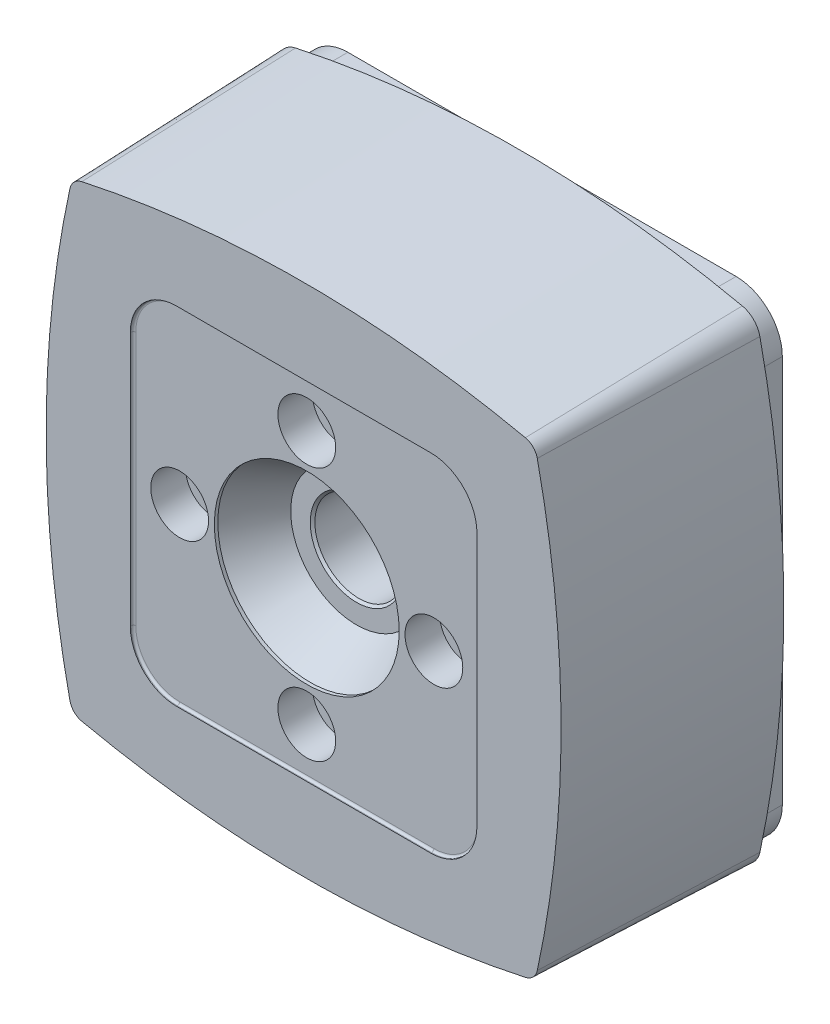
from build123d import *

# Parameters (mm, degrees)
EXTRUDE1_DEPTH      = 93.15
EXTRUDE1_TAPER      = 2
CUT_EXTRUDE1_DEPTH  = 1.37
FILLET1_R           = 1
SKETCH3_R           = 40
CUT_EXTRUDE2_DEPTH  = 1.5
SKETCH4_R           = 19
CUT_EXTRUDE3_DEPTH  = 175.5
SKETCH5_R           = 40
CUT_EXTRUDE4_DEPTH  = 20
CUT_EXTRUDE4_DRAFT  = -30
CHAMFER1_SIZE       = 1
EXTRUDE2_DEPTH      = 10
SKETCH7_R           = 19
CUT_EXTRUDE5_DEPTH  = 77
SKETCH8_R           = 12.5
CUT_EXTRUDE6_DEPTH  = 15
SKETCH9_R           = 5.857190083
SKETCH9_R_2         = 6.949090909
SKETCH9_R_3         = 6.10677686
SKETCH9_R_4         = 7.5
CUT_EXTRUDE7_DEPTH  = 15
SKETCH10_R          = 7.5
CUT_EXTRUDE8_DEPTH  = 201
SKETCH11_R          = 12.5
SKETCH11_R_2        = 9.5
CUT_EXTRUDE9_DEPTH  = 1.5
SKETCH12_R          = 8
CUT_EXTRUDE10_DEPTH = 70
SKETCH14_R          = 7
CUT_EXTRUDE12_DEPTH = 40


with BuildPart() as part:
    # Sketch1 → Extrude1 (new body)
    with BuildSketch(Plane.XY):
        with BuildLine():
            ThreePointArc((104.294853405, -96.642942622), (114.66, 0), (104.294853405, 96.642942622))
            ThreePointArc((104.294853405, 96.642942622), (101.593364666, 101.593364666), (96.642942622, 104.294853405))
            ThreePointArc((96.642942622, 104.294853405), (0, 114.66), (-96.642942622, 104.294853405))
            ThreePointArc((-96.642942622, 104.294853405), (-101.593364666, 101.593364666), (-104.294853405, 96.642942622))
            ThreePointArc((-104.294853405, 96.642942622), (-114.66, 0), (-104.294853405, -96.642942622))
            ThreePointArc((-104.294853405, -96.642942622), (-101.593364666, -101.593364666), (-96.642942622, -104.294853405))
            ThreePointArc((-96.642942622, -104.294853405), (0, -114.66), (96.642942622, -104.294853405))
            ThreePointArc((96.642942622, -104.294853405), (101.593364666, -101.593364666), (104.294853405, -96.642942622))
        make_face()
    extrude(amount=EXTRUDE1_DEPTH, taper=EXTRUDE1_TAPER)

    # Sketch2 → Cut-Extrude1 (cut)
    with BuildSketch(Plane.XY.offset(93.15)):
        with BuildLine():
            Line((-55, -75), (55, -75))
            ThreePointArc((55, -75), (69.142135624, -69.142135624), (75, -55))
            Line((75, -55), (75, 55))
            ThreePointArc((75, 55), (69.142135624, 69.142135624), (55, 75))
            Line((55, 75), (-55, 75))
            ThreePointArc((-55, 75), (-69.142135624, 69.142135624), (-75, 55))
            Line((-75, 55), (-75, -55))
            ThreePointArc((-75, -55), (-69.142135624, -69.142135624), (-55, -75))
        make_face()
    extrude(amount=-CUT_EXTRUDE1_DEPTH, mode=Mode.SUBTRACT)

    # Fillet1
    fillet1_edges = [part.edges().sort_by_distance(p)[0] for p in [
        (69.142135624, 69.142135624, 91.78),
        (75, 0, 91.78),
        (69.142135624, -69.142135624, 91.78),
        (0, -75, 91.78),
        (-69.142135624, -69.142135624, 91.78),
        (-75, 0, 91.78),
        (-69.142135624, 69.142135624, 91.78),
        (0, 75, 91.78),
    ]]
    fillet(fillet1_edges, radius=FILLET1_R)

    # Sketch3 → Cut-Extrude2 (cut)
    with BuildSketch(Plane.XY.offset(91.78)):
        Circle(SKETCH3_R)
    extrude(amount=-CUT_EXTRUDE2_DEPTH, mode=Mode.SUBTRACT)

    # Sketch4 → Cut-Extrude3 (cut)
    with BuildSketch(Plane.XY.offset(90.28)):
        Circle(SKETCH4_R)
    extrude(amount=-CUT_EXTRUDE3_DEPTH, mode=Mode.SUBTRACT)


with BuildPart() as cut_extrude4_tool:
    # Sketch5 → Cut-Extrude4 (with draft: the straight prism first)
    with BuildSketch(Plane.XY.offset(90.28)):
        Circle(SKETCH5_R)
    extrude(amount=-CUT_EXTRUDE4_DEPTH)
    # Cut-Extrude4: the draft: its side faces are tilted about the plane it starts from
    cut_extrude4_sides = [cut_extrude4_tool.faces().sort_by_distance(p)[0] for p in [
        (-40, 0, 80.28),
    ]]
    draft(cut_extrude4_sides, Plane.XY.offset(90.28), CUT_EXTRUDE4_DRAFT)


with BuildPart() as part_1:
    add(part.part)

    # Cut-Extrude4: cut by cut_extrude4_tool
    add(cut_extrude4_tool.part, mode=Mode.SUBTRACT)

    # Chamfer1
    chamfer1_edges = [part_1.edges().sort_by_distance(p)[0] for p in [
        (-19, 0, 70.28),
    ]]
    chamfer(chamfer1_edges, length=CHAMFER1_SIZE)

    # Sketch6 → Extrude2 (add)
    with BuildSketch(Plane(origin=(0, 0, 0), x_dir=(-1, 0, 0), z_dir=(0, 0, -1))):
        with BuildLine():
            Line((-84, -104), (84, -104))
            ThreePointArc((84, -104), (98.142135624, -98.142135624), (104, -84))
            Line((104, -84), (104, 84))
            ThreePointArc((104, 84), (98.142135624, 98.142135624), (84, 104))
            Line((84, 104), (-84, 104))
            ThreePointArc((-84, 104), (-98.142135624, 98.142135624), (-104, 84))
            Line((-104, 84), (-104, -84))
            ThreePointArc((-104, -84), (-98.142135624, -98.142135624), (-84, -104))
        make_face()
    extrude(amount=EXTRUDE2_DEPTH)

    # Sketch7 → Cut-Extrude5 (cut)
    with BuildSketch(Plane.XY):
        Circle(SKETCH7_R)
    extrude(amount=-CUT_EXTRUDE5_DEPTH, mode=Mode.SUBTRACT)

    # Sketch8 → Cut-Extrude6 (cut)
    with BuildSketch(Plane.XY.offset(91.78)):
        with Locations((-55, 0)):
            Circle(SKETCH8_R)
        with Locations((55, 0)):
            Circle(SKETCH8_R)
        with Locations((0, 55)):
            Circle(SKETCH8_R)
        with Locations((0, -55)):
            Circle(SKETCH8_R)
    extrude(amount=-CUT_EXTRUDE6_DEPTH, mode=Mode.SUBTRACT)

    # Sketch9 → Cut-Extrude7 (cut)
    with BuildSketch(Plane.XY.offset(76.78)):
        with Locations((0, 55)):
            Circle(SKETCH9_R)
        with Locations((-55, 0)):
            Circle(SKETCH9_R_2)
        with Locations((55, 0)):
            Circle(SKETCH9_R_3)
        with Locations((0, -55)):
            Circle(SKETCH9_R_4)
    extrude(amount=-CUT_EXTRUDE7_DEPTH, mode=Mode.SUBTRACT)

    # Sketch10 → Cut-Extrude8 (cut)
    with BuildSketch(Plane.XY.offset(76.78)):
        with Locations((0, 55)):
            Circle(SKETCH10_R)
        with Locations((55, 0)):
            Circle(SKETCH10_R)
        with Locations((0, -55)):
            Circle(SKETCH10_R)
        with Locations((-55, 0)):
            Circle(SKETCH10_R)
    extrude(amount=-CUT_EXTRUDE8_DEPTH, mode=Mode.SUBTRACT)

    # Sketch11 → Cut-Extrude9 (cut)
    # profile 1 of 12: a face of its own
    with BuildSketch(Plane(origin=(0, 0, -10), x_dir=(-1, 0, 0), z_dir=(0, 0, -1))):
        with Locations((-84, -84)):
            Circle(SKETCH11_R)
        with Locations((-84, -84)):
            Circle(SKETCH11_R_2, mode=Mode.SUBTRACT)
    # profile 2 of 12: a face of its own
    with BuildSketch(Plane(origin=(0, 0, -10), x_dir=(-1, 0, 0), z_dir=(0, 0, -1))):
        with Locations((-28, -84)):
            Circle(SKETCH11_R)
        with Locations((-28, -84)):
            Circle(SKETCH11_R_2, mode=Mode.SUBTRACT)
    # profile 3 of 12: a face of its own
    with BuildSketch(Plane(origin=(0, 0, -10), x_dir=(-1, 0, 0), z_dir=(0, 0, -1))):
        with Locations((28, -84)):
            Circle(SKETCH11_R)
        with Locations((28, -84)):
            Circle(SKETCH11_R_2, mode=Mode.SUBTRACT)
    # profile 4 of 12: a face of its own
    with BuildSketch(Plane(origin=(0, 0, -10), x_dir=(-1, 0, 0), z_dir=(0, 0, -1))):
        with Locations((84, -84)):
            Circle(SKETCH11_R)
        with Locations((84, -84)):
            Circle(SKETCH11_R_2, mode=Mode.SUBTRACT)
    # profile 5 of 12: a face of its own
    with BuildSketch(Plane(origin=(0, 0, -10), x_dir=(-1, 0, 0), z_dir=(0, 0, -1))):
        with Locations((84, -28)):
            Circle(SKETCH11_R)
        with Locations((84, -28)):
            Circle(SKETCH11_R_2, mode=Mode.SUBTRACT)
    # profile 6 of 12: a face of its own
    with BuildSketch(Plane(origin=(0, 0, -10), x_dir=(-1, 0, 0), z_dir=(0, 0, -1))):
        with Locations((84, 28)):
            Circle(SKETCH11_R)
        with Locations((84, 28)):
            Circle(SKETCH11_R_2, mode=Mode.SUBTRACT)
    # profile 7 of 12: a face of its own
    with BuildSketch(Plane(origin=(0, 0, -10), x_dir=(-1, 0, 0), z_dir=(0, 0, -1))):
        with Locations((84, 84)):
            Circle(SKETCH11_R)
        with Locations((84, 84)):
            Circle(SKETCH11_R_2, mode=Mode.SUBTRACT)
    # profile 8 of 12: a face of its own
    with BuildSketch(Plane(origin=(0, 0, -10), x_dir=(-1, 0, 0), z_dir=(0, 0, -1))):
        with Locations((28, 84)):
            Circle(SKETCH11_R)
        with Locations((28, 84)):
            Circle(SKETCH11_R_2, mode=Mode.SUBTRACT)
    # profile 9 of 12: a face of its own
    with BuildSketch(Plane(origin=(0, 0, -10), x_dir=(-1, 0, 0), z_dir=(0, 0, -1))):
        with Locations((-28, 84)):
            Circle(SKETCH11_R)
        with Locations((-28, 84)):
            Circle(SKETCH11_R_2, mode=Mode.SUBTRACT)
    # profile 10 of 12: a face of its own
    with BuildSketch(Plane(origin=(0, 0, -10), x_dir=(-1, 0, 0), z_dir=(0, 0, -1))):
        with Locations((-84, 84)):
            Circle(SKETCH11_R)
        with Locations((-84, 84)):
            Circle(SKETCH11_R_2, mode=Mode.SUBTRACT)
    # profile 11 of 12: a face of its own
    with BuildSketch(Plane(origin=(0, 0, -10), x_dir=(-1, 0, 0), z_dir=(0, 0, -1))):
        with Locations((-84, 28)):
            Circle(SKETCH11_R)
        with Locations((-84, 28)):
            Circle(SKETCH11_R_2, mode=Mode.SUBTRACT)
    # profile 12 of 12: a face of its own
    with BuildSketch(Plane(origin=(0, 0, -10), x_dir=(-1, 0, 0), z_dir=(0, 0, -1))):
        with Locations((-84, -28)):
            Circle(SKETCH11_R)
        with Locations((-84, -28)):
            Circle(SKETCH11_R_2, mode=Mode.SUBTRACT)
    extrude(amount=-CUT_EXTRUDE9_DEPTH, mode=Mode.SUBTRACT)

    # Sketch12 → Cut-Extrude10 (cut)
    with BuildSketch(Plane(origin=(0, 0, -10), x_dir=(-1, 0, 0), z_dir=(0, 0, -1))):
        with Locations((-84, -84)):
            Circle(SKETCH12_R)
        with Locations((-28, -84)):
            Circle(SKETCH12_R)
        with Locations((28, -84)):
            Circle(SKETCH12_R)
        with Locations((84, -84)):
            Circle(SKETCH12_R)
        with Locations((84, -28)):
            Circle(SKETCH12_R)
        with Locations((84, 28)):
            Circle(SKETCH12_R)
        with Locations((84, 84)):
            Circle(SKETCH12_R)
        with Locations((28, 84)):
            Circle(SKETCH12_R)
        with Locations((-28, 84)):
            Circle(SKETCH12_R)
        with Locations((-84, 84)):
            Circle(SKETCH12_R)
        with Locations((-84, 28)):
            Circle(SKETCH12_R)
        with Locations((-84, -28)):
            Circle(SKETCH12_R)
    extrude(amount=-CUT_EXTRUDE10_DEPTH, mode=Mode.SUBTRACT)

    # Cut-Extrude11 cone 1 section (through the dimple's axis) → Cut-Extrude11 (revolve, cut)
    with BuildSketch(Plane(origin=(-84, 84, 60), x_dir=(0, 1, 0), z_dir=(1, 0, 0))):
        Polygon((0, 0), (8, 0), (0, 4.618802154), align=None)
    revolve(axis=Axis((-84, 84, 60), (0, 0, 1)), mode=Mode.SUBTRACT)

    # Cut-Extrude11 cone 2 section (through the dimple's axis) → Cut-Extrude11 cone 2 (revolve, cut)
    with BuildSketch(Plane(origin=(-28, 84, 60), x_dir=(0, 1, 0), z_dir=(1, 0, 0))):
        Polygon((0, 0), (8, 0), (0, 4.618802154), align=None)
    revolve(axis=Axis((-28, 84, 60), (0, 0, 1)), mode=Mode.SUBTRACT)

    # Cut-Extrude11 cone 3 section (through the dimple's axis) → Cut-Extrude11 cone 3 (revolve, cut)
    with BuildSketch(Plane(origin=(28, 84, 60), x_dir=(0, 1, 0), z_dir=(1, 0, 0))):
        Polygon((0, 0), (8, 0), (0, 4.618802154), align=None)
    revolve(axis=Axis((28, 84, 60), (0, 0, 1)), mode=Mode.SUBTRACT)

    # Cut-Extrude11 cone 4 section (through the dimple's axis) → Cut-Extrude11 cone 4 (revolve, cut)
    with BuildSketch(Plane(origin=(84, 84, 60), x_dir=(0, 1, 0), z_dir=(1, 0, 0))):
        Polygon((0, 0), (8, 0), (0, 4.618802154), align=None)
    revolve(axis=Axis((84, 84, 60), (0, 0, 1)), mode=Mode.SUBTRACT)

    # Cut-Extrude11 cone 5 section (through the dimple's axis) → Cut-Extrude11 cone 5 (revolve, cut)
    with BuildSketch(Plane(origin=(84, 28, 60), x_dir=(0, 1, 0), z_dir=(1, 0, 0))):
        Polygon((0, 0), (8, 0), (0, 4.618802154), align=None)
    revolve(axis=Axis((84, 28, 60), (0, 0, 1)), mode=Mode.SUBTRACT)

    # Cut-Extrude11 cone 6 section (through the dimple's axis) → Cut-Extrude11 cone 6 (revolve, cut)
    with BuildSketch(Plane(origin=(84, -28, 60), x_dir=(0, 1, 0), z_dir=(1, 0, 0))):
        Polygon((0, 0), (8, 0), (0, 4.618802154), align=None)
    revolve(axis=Axis((84, -28, 60), (0, 0, 1)), mode=Mode.SUBTRACT)

    # Cut-Extrude11 cone 7 section (through the dimple's axis) → Cut-Extrude11 cone 7 (revolve, cut)
    with BuildSketch(Plane(origin=(-84, 28, 60), x_dir=(0, 1, 0), z_dir=(1, 0, 0))):
        Polygon((0, 0), (8, 0), (0, 4.618802154), align=None)
    revolve(axis=Axis((-84, 28, 60), (0, 0, 1)), mode=Mode.SUBTRACT)

    # Cut-Extrude11 cone 8 section (through the dimple's axis) → Cut-Extrude11 cone 8 (revolve, cut)
    with BuildSketch(Plane(origin=(-84, -28, 60), x_dir=(0, 1, 0), z_dir=(1, 0, 0))):
        Polygon((0, 0), (8, 0), (0, 4.618802154), align=None)
    revolve(axis=Axis((-84, -28, 60), (0, 0, 1)), mode=Mode.SUBTRACT)

    # Cut-Extrude11 cone 9 section (through the dimple's axis) → Cut-Extrude11 cone 9 (revolve, cut)
    with BuildSketch(Plane(origin=(84, -84, 60), x_dir=(0, 1, 0), z_dir=(1, 0, 0))):
        Polygon((0, 0), (8, 0), (0, 4.618802154), align=None)
    revolve(axis=Axis((84, -84, 60), (0, 0, 1)), mode=Mode.SUBTRACT)

    # Cut-Extrude11 cone 10 section (through the dimple's axis) → Cut-Extrude11 cone 10 (revolve, cut)
    with BuildSketch(Plane(origin=(28, -84, 60), x_dir=(0, 1, 0), z_dir=(1, 0, 0))):
        Polygon((0, 0), (8, 0), (0, 4.618802154), align=None)
    revolve(axis=Axis((28, -84, 60), (0, 0, 1)), mode=Mode.SUBTRACT)

    # Cut-Extrude11 cone 11 section (through the dimple's axis) → Cut-Extrude11 cone 11 (revolve, cut)
    with BuildSketch(Plane(origin=(-28, -84, 60), x_dir=(0, 1, 0), z_dir=(1, 0, 0))):
        Polygon((0, 0), (8, 0), (0, 4.618802154), align=None)
    revolve(axis=Axis((-28, -84, 60), (0, 0, 1)), mode=Mode.SUBTRACT)

    # Cut-Extrude11 cone 12 section (through the dimple's axis) → Cut-Extrude11 cone 12 (revolve, cut)
    with BuildSketch(Plane(origin=(-84, -84, 60), x_dir=(0, 1, 0), z_dir=(1, 0, 0))):
        Polygon((0, 0), (8, 0), (0, 4.618802154), align=None)
    revolve(axis=Axis((-84, -84, 60), (0, 0, 1)), mode=Mode.SUBTRACT)

    # Sketch14 → Cut-Extrude12 (cut)
    with BuildSketch(Plane(origin=(0, 0, -10), x_dir=(-1, 0, 0), z_dir=(0, 0, -1))):
        with Locations((-56, -84)):
            Circle(SKETCH14_R)
        with Locations((0, -84)):
            Circle(SKETCH14_R)
        with Locations((56, -84)):
            Circle(SKETCH14_R)
        with Locations((84, -56)):
            Circle(SKETCH14_R)
        with Locations((84, 0)):
            Circle(SKETCH14_R)
        with Locations((84, 56)):
            Circle(SKETCH14_R)
        with Locations((56, 84)):
            Circle(SKETCH14_R)
        with Locations((0, 84)):
            Circle(SKETCH14_R)
        with Locations((-56, 84)):
            Circle(SKETCH14_R)
        with Locations((-84, 56)):
            Circle(SKETCH14_R)
        with Locations((-84, 0)):
            Circle(SKETCH14_R)
        with Locations((-84, -56)):
            Circle(SKETCH14_R)
    extrude(amount=-CUT_EXTRUDE12_DEPTH, mode=Mode.SUBTRACT)

    # Cut-Extrude13 cone 1 section (through the dimple's axis) → Cut-Extrude13 (revolve, cut)
    with BuildSketch(Plane(origin=(0, 84, 30), x_dir=(0, 1, 0), z_dir=(1, 0, 0))):
        Polygon((0, 0), (7, 0), (0, 4.041451884), align=None)
    revolve(axis=Axis((0, 84, 30), (0, 0, 1)), mode=Mode.SUBTRACT)

    # Cut-Extrude13 cone 2 section (through the dimple's axis) → Cut-Extrude13 cone 2 (revolve, cut)
    with BuildSketch(Plane(origin=(-56, 84, 30), x_dir=(0, 1, 0), z_dir=(1, 0, 0))):
        Polygon((0, 0), (7, 0), (0, 4.041451884), align=None)
    revolve(axis=Axis((-56, 84, 30), (0, 0, 1)), mode=Mode.SUBTRACT)

    # Cut-Extrude13 cone 3 section (through the dimple's axis) → Cut-Extrude13 cone 3 (revolve, cut)
    with BuildSketch(Plane(origin=(56, 84, 30), x_dir=(0, 1, 0), z_dir=(1, 0, 0))):
        Polygon((0, 0), (7, 0), (0, 4.041451884), align=None)
    revolve(axis=Axis((56, 84, 30), (0, 0, 1)), mode=Mode.SUBTRACT)

    # Cut-Extrude13 cone 4 section (through the dimple's axis) → Cut-Extrude13 cone 4 (revolve, cut)
    with BuildSketch(Plane(origin=(84, 56, 30), x_dir=(0, 1, 0), z_dir=(1, 0, 0))):
        Polygon((0, 0), (7, 0), (0, 4.041451884), align=None)
    revolve(axis=Axis((84, 56, 30), (0, 0, 1)), mode=Mode.SUBTRACT)

    # Cut-Extrude13 cone 5 section (through the dimple's axis) → Cut-Extrude13 cone 5 (revolve, cut)
    with BuildSketch(Plane(origin=(84, 0, 30), x_dir=(0, 1, 0), z_dir=(1, 0, 0))):
        Polygon((0, 0), (7, 0), (0, 4.041451884), align=None)
    revolve(axis=Axis((84, 0, 30), (0, 0, 1)), mode=Mode.SUBTRACT)

    # Cut-Extrude13 cone 6 section (through the dimple's axis) → Cut-Extrude13 cone 6 (revolve, cut)
    with BuildSketch(Plane(origin=(84, -56, 30), x_dir=(0, 1, 0), z_dir=(1, 0, 0))):
        Polygon((0, 0), (7, 0), (0, 4.041451884), align=None)
    revolve(axis=Axis((84, -56, 30), (0, 0, 1)), mode=Mode.SUBTRACT)

    # Cut-Extrude13 cone 7 section (through the dimple's axis) → Cut-Extrude13 cone 7 (revolve, cut)
    with BuildSketch(Plane(origin=(56, -84, 30), x_dir=(0, 1, 0), z_dir=(1, 0, 0))):
        Polygon((0, 0), (7, 0), (0, 4.041451884), align=None)
    revolve(axis=Axis((56, -84, 30), (0, 0, 1)), mode=Mode.SUBTRACT)

    # Cut-Extrude13 cone 8 section (through the dimple's axis) → Cut-Extrude13 cone 8 (revolve, cut)
    with BuildSketch(Plane(origin=(0, -84, 30), x_dir=(0, 1, 0), z_dir=(1, 0, 0))):
        Polygon((0, 0), (7, 0), (0, 4.041451884), align=None)
    revolve(axis=Axis((0, -84, 30), (0, 0, 1)), mode=Mode.SUBTRACT)

    # Cut-Extrude13 cone 9 section (through the dimple's axis) → Cut-Extrude13 cone 9 (revolve, cut)
    with BuildSketch(Plane(origin=(-56, -84, 30), x_dir=(0, 1, 0), z_dir=(1, 0, 0))):
        Polygon((0, 0), (7, 0), (0, 4.041451884), align=None)
    revolve(axis=Axis((-56, -84, 30), (0, 0, 1)), mode=Mode.SUBTRACT)

    # Cut-Extrude13 cone 10 section (through the dimple's axis) → Cut-Extrude13 cone 10 (revolve, cut)
    with BuildSketch(Plane(origin=(-84, -56, 30), x_dir=(0, 1, 0), z_dir=(1, 0, 0))):
        Polygon((0, 0), (7, 0), (0, 4.041451884), align=None)
    revolve(axis=Axis((-84, -56, 30), (0, 0, 1)), mode=Mode.SUBTRACT)

    # Cut-Extrude13 cone 11 section (through the dimple's axis) → Cut-Extrude13 cone 11 (revolve, cut)
    with BuildSketch(Plane(origin=(-84, 0, 30), x_dir=(0, 1, 0), z_dir=(1, 0, 0))):
        Polygon((0, 0), (7, 0), (0, 4.041451884), align=None)
    revolve(axis=Axis((-84, 0, 30), (0, 0, 1)), mode=Mode.SUBTRACT)

    # Cut-Extrude13 cone 12 section (through the dimple's axis) → Cut-Extrude13 cone 12 (revolve, cut)
    with BuildSketch(Plane(origin=(-84, 56, 30), x_dir=(0, 1, 0), z_dir=(1, 0, 0))):
        Polygon((0, 0), (7, 0), (0, 4.041451884), align=None)
    revolve(axis=Axis((-84, 56, 30), (0, 0, 1)), mode=Mode.SUBTRACT)


solid = part_1.part
